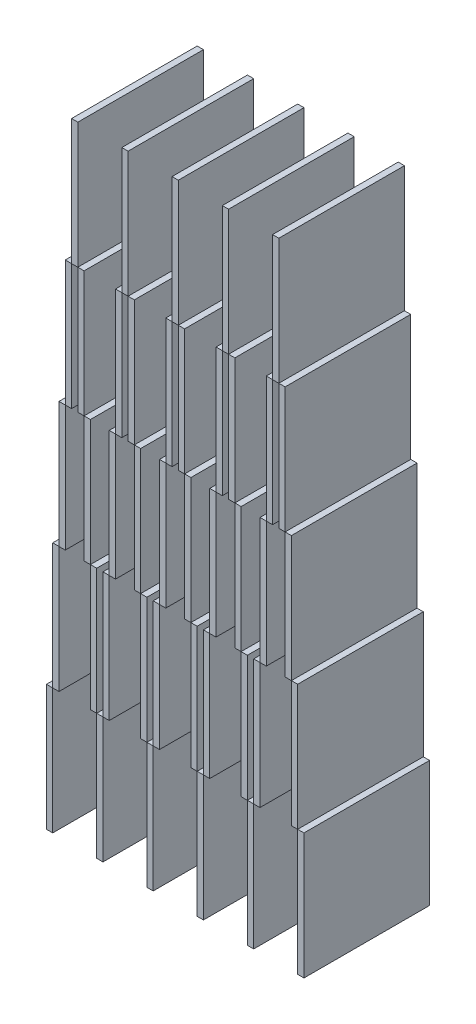
from build123d import *

# Parameters (mm, degrees)
SKETCH1_W              = 1
SKETCH1_H              = 20
BOSS_EXTRUDE1_DEPTH    = 20
BOSS_EXTRUDE1_2_DEPTH  = 20
BOSS_EXTRUDE1_3_DEPTH  = 20
BOSS_EXTRUDE1_4_DEPTH  = 20
BOSS_EXTRUDE1_5_DEPTH  = 20
BOSS_EXTRUDE1_6_DEPTH  = 20
BOSS_EXTRUDE1_7_DEPTH  = 20
BOSS_EXTRUDE1_8_DEPTH  = 20
BOSS_EXTRUDE1_9_DEPTH  = 20
BOSS_EXTRUDE1_10_DEPTH = 20
BOSS_EXTRUDE1_11_DEPTH = 20
BOSS_EXTRUDE1_12_DEPTH = 20
BOSS_EXTRUDE1_13_DEPTH = 20
BOSS_EXTRUDE1_14_DEPTH = 20
BOSS_EXTRUDE1_15_DEPTH = 20
BOSS_EXTRUDE1_16_DEPTH = 20
BOSS_EXTRUDE1_17_DEPTH = 20
BOSS_EXTRUDE1_18_DEPTH = 20
BOSS_EXTRUDE1_19_DEPTH = 20
BOSS_EXTRUDE1_20_DEPTH = 20
BOSS_EXTRUDE1_21_DEPTH = 20
BOSS_EXTRUDE1_22_DEPTH = 20
BOSS_EXTRUDE1_23_DEPTH = 20
BOSS_EXTRUDE1_24_DEPTH = 20
BOSS_EXTRUDE1_25_DEPTH = 20
BOSS_EXTRUDE1_26_DEPTH = 20
BOSS_EXTRUDE1_27_DEPTH = 20
BOSS_EXTRUDE1_28_DEPTH = 20
BOSS_EXTRUDE1_29_DEPTH = 20
BOSS_EXTRUDE1_30_DEPTH = 20
BOSS_EXTRUDE1_31_DEPTH = 20
BOSS_EXTRUDE1_32_DEPTH = 20
BOSS_EXTRUDE1_33_DEPTH = 20
BOSS_EXTRUDE1_34_DEPTH = 20
BOSS_EXTRUDE1_35_DEPTH = 20
BOSS_EXTRUDE1_36_DEPTH = 20
BOSS_EXTRUDE1_37_DEPTH = 20
BOSS_EXTRUDE1_38_DEPTH = 20
BOSS_EXTRUDE1_39_DEPTH = 20
BOSS_EXTRUDE1_40_DEPTH = 20
BOSS_EXTRUDE1_41_DEPTH = 20


with BuildPart() as part:
    # Sketch1 → Boss-Extrude1 (new body)
    with BuildSketch(Plane.XY):
        with Locations((-46.033972916, 14.88459588)):
            Rectangle(SKETCH1_W, SKETCH1_H)
    extrude(amount=BOSS_EXTRUDE1_DEPTH)


with BuildPart() as body_2:
    # Sketch1 → Boss-Extrude1 2 (new body)
    with BuildSketch(Plane.XY):
        with Locations((-45.033972916, 34.88459588)):
            Rectangle(SKETCH1_W, SKETCH1_H)
    extrude(amount=BOSS_EXTRUDE1_2_DEPTH)


with BuildPart() as body_3:
    # Sketch1 → Boss-Extrude1 3 (new body)
    with BuildSketch(Plane.XY):
        with Locations((-39.033972916, 34.88459588)):
            Rectangle(SKETCH1_W, SKETCH1_H)
    extrude(amount=BOSS_EXTRUDE1_3_DEPTH)


with BuildPart() as body_4:
    # Sketch1 → Boss-Extrude1 4 (new body)
    with BuildSketch(Plane.XY):
        with Locations((-37.033972916, 34.88459588)):
            Rectangle(SKETCH1_W, SKETCH1_H)
    extrude(amount=BOSS_EXTRUDE1_4_DEPTH)


with BuildPart() as body_5:
    # Sketch1 → Boss-Extrude1 5 (new body)
    with BuildSketch(Plane.XY):
        with Locations((-38.033972916, 14.88459588)):
            Rectangle(SKETCH1_W, SKETCH1_H)
    extrude(amount=BOSS_EXTRUDE1_5_DEPTH)


with BuildPart() as body_6:
    # Sketch1 → Boss-Extrude1 6 (new body)
    with BuildSketch(Plane.XY):
        with Locations((-31.033972916, 34.88459588)):
            Rectangle(SKETCH1_W, SKETCH1_H)
    extrude(amount=BOSS_EXTRUDE1_6_DEPTH)


with BuildPart() as body_7:
    # Sketch1 → Boss-Extrude1 7 (new body)
    with BuildSketch(Plane.XY):
        with Locations((-29.033972916, 34.88459588)):
            Rectangle(SKETCH1_W, SKETCH1_H)
    extrude(amount=BOSS_EXTRUDE1_7_DEPTH)


with BuildPart() as body_8:
    # Sketch1 → Boss-Extrude1 8 (new body)
    with BuildSketch(Plane.XY):
        with Locations((-30.033972916, 14.88459588)):
            Rectangle(SKETCH1_W, SKETCH1_H)
    extrude(amount=BOSS_EXTRUDE1_8_DEPTH)


with BuildPart() as body_9:
    # Sketch1 → Boss-Extrude1 9 (new body)
    with BuildSketch(Plane.XY):
        with Locations((-23.033972916, 34.88459588)):
            Rectangle(SKETCH1_W, SKETCH1_H)
    extrude(amount=BOSS_EXTRUDE1_9_DEPTH)


with BuildPart() as body_10:
    # Sketch1 → Boss-Extrude1 10 (new body)
    with BuildSketch(Plane.XY):
        with Locations((-21.033972916, 34.88459588)):
            Rectangle(SKETCH1_W, SKETCH1_H)
    extrude(amount=BOSS_EXTRUDE1_10_DEPTH)


with BuildPart() as body_11:
    # Sketch1 → Boss-Extrude1 11 (new body)
    with BuildSketch(Plane.XY):
        with Locations((-22.033972916, 14.88459588)):
            Rectangle(SKETCH1_W, SKETCH1_H)
    extrude(amount=BOSS_EXTRUDE1_11_DEPTH)


with BuildPart() as body_12:
    # Sketch1 → Boss-Extrude1 12 (new body)
    with BuildSketch(Plane.XY):
        with Locations((-6.033972916, 14.88459588)):
            Rectangle(SKETCH1_W, SKETCH1_H)
    extrude(amount=BOSS_EXTRUDE1_12_DEPTH)


with BuildPart() as body_13:
    # Sketch1 → Boss-Extrude1 13 (new body)
    with BuildSketch(Plane.XY):
        with Locations((-14.033972916, 14.88459588)):
            Rectangle(SKETCH1_W, SKETCH1_H)
    extrude(amount=BOSS_EXTRUDE1_13_DEPTH)


with BuildPart() as body_14:
    # Sketch1 → Boss-Extrude1 14 (new body)
    with BuildSketch(Plane.XY):
        with Locations((-15.033972916, 34.88459588)):
            Rectangle(SKETCH1_W, SKETCH1_H)
    extrude(amount=BOSS_EXTRUDE1_14_DEPTH)


with BuildPart() as body_15:
    # Sketch1 → Boss-Extrude1 15 (new body)
    with BuildSketch(Plane.XY):
        with Locations((-13.033972916, 34.88459588)):
            Rectangle(SKETCH1_W, SKETCH1_H)
    extrude(amount=BOSS_EXTRUDE1_15_DEPTH)


with BuildPart() as body_16:
    # Sketch1 → Boss-Extrude1 16 (new body)
    with BuildSketch(Plane.XY):
        with Locations((-7.033972916, 34.88459588)):
            Rectangle(SKETCH1_W, SKETCH1_H)
    extrude(amount=BOSS_EXTRUDE1_16_DEPTH)


with BuildPart() as body_17:
    # Sketch1 → Boss-Extrude1 17 (new body)
    with BuildSketch(Plane.XY):
        with Locations((-44.033972916, 54.88459588)):
            Rectangle(SKETCH1_W, SKETCH1_H)
    extrude(amount=BOSS_EXTRUDE1_17_DEPTH)


with BuildPart() as body_18:
    # Sketch1 → Boss-Extrude1 18 (new body)
    with BuildSketch(Plane.XY):
        with Locations((-36.033972916, 54.88459588)):
            Rectangle(SKETCH1_W, SKETCH1_H)
    extrude(amount=BOSS_EXTRUDE1_18_DEPTH)


with BuildPart() as body_19:
    # Sketch1 → Boss-Extrude1 19 (new body)
    with BuildSketch(Plane.XY):
        with Locations((-32.033972916, 54.88459588)):
            Rectangle(SKETCH1_W, SKETCH1_H)
    extrude(amount=BOSS_EXTRUDE1_19_DEPTH)


with BuildPart() as body_20:
    # Sketch1 → Boss-Extrude1 20 (new body)
    with BuildSketch(Plane.XY):
        with Locations((-43.033972916, 74.88459588)):
            Rectangle(SKETCH1_W, SKETCH1_H)
    extrude(amount=BOSS_EXTRUDE1_20_DEPTH)


with BuildPart() as body_21:
    # Sketch1 → Boss-Extrude1 21 (new body)
    with BuildSketch(Plane.XY):
        with Locations((-41.033972916, 74.88459588)):
            Rectangle(SKETCH1_W, SKETCH1_H)
    extrude(amount=BOSS_EXTRUDE1_21_DEPTH)


with BuildPart() as body_22:
    # Sketch1 → Boss-Extrude1 22 (new body)
    with BuildSketch(Plane.XY):
        with Locations((-35.033972916, 74.88459588)):
            Rectangle(SKETCH1_W, SKETCH1_H)
    extrude(amount=BOSS_EXTRUDE1_22_DEPTH)


with BuildPart() as body_23:
    # Sketch1 → Boss-Extrude1 23 (new body)
    with BuildSketch(Plane.XY):
        with Locations((-33.033972916, 74.88459588)):
            Rectangle(SKETCH1_W, SKETCH1_H)
    extrude(amount=BOSS_EXTRUDE1_23_DEPTH)


with BuildPart() as body_24:
    # Sketch1 → Boss-Extrude1 24 (new body)
    with BuildSketch(Plane.XY):
        with Locations((-28.033972916, 54.88459588)):
            Rectangle(SKETCH1_W, SKETCH1_H)
    extrude(amount=BOSS_EXTRUDE1_24_DEPTH)


with BuildPart() as body_25:
    # Sketch1 → Boss-Extrude1 25 (new body)
    with BuildSketch(Plane.XY):
        with Locations((-27.033972916, 74.88459588)):
            Rectangle(SKETCH1_W, SKETCH1_H)
    extrude(amount=BOSS_EXTRUDE1_25_DEPTH)


with BuildPart() as body_26:
    # Sketch1 → Boss-Extrude1 26 (new body)
    with BuildSketch(Plane.XY):
        with Locations((-25.033972916, 74.88459588)):
            Rectangle(SKETCH1_W, SKETCH1_H)
    extrude(amount=BOSS_EXTRUDE1_26_DEPTH)


with BuildPart() as body_27:
    # Sketch1 → Boss-Extrude1 27 (new body)
    with BuildSketch(Plane.XY):
        with Locations((-24.033972916, 54.88459588)):
            Rectangle(SKETCH1_W, SKETCH1_H)
    extrude(amount=BOSS_EXTRUDE1_27_DEPTH)


with BuildPart() as body_28:
    # Sketch1 → Boss-Extrude1 28 (new body)
    with BuildSketch(Plane.XY):
        with Locations((-20.033972916, 54.88459588)):
            Rectangle(SKETCH1_W, SKETCH1_H)
    extrude(amount=BOSS_EXTRUDE1_28_DEPTH)


with BuildPart() as body_29:
    # Sketch1 → Boss-Extrude1 29 (new body)
    with BuildSketch(Plane.XY):
        with Locations((-19.033972916, 74.88459588)):
            Rectangle(SKETCH1_W, SKETCH1_H)
    extrude(amount=BOSS_EXTRUDE1_29_DEPTH)


with BuildPart() as body_30:
    # Sketch1 → Boss-Extrude1 30 (new body)
    with BuildSketch(Plane.XY):
        with Locations((-17.033972916, 74.88459588)):
            Rectangle(SKETCH1_W, SKETCH1_H)
    extrude(amount=BOSS_EXTRUDE1_30_DEPTH)


with BuildPart() as body_31:
    # Sketch1 → Boss-Extrude1 31 (new body)
    with BuildSketch(Plane.XY):
        with Locations((-16.033972916, 54.88459588)):
            Rectangle(SKETCH1_W, SKETCH1_H)
    extrude(amount=BOSS_EXTRUDE1_31_DEPTH)


with BuildPart() as body_32:
    # Sketch1 → Boss-Extrude1 32 (new body)
    with BuildSketch(Plane.XY):
        with Locations((-12.033972916, 54.88459588)):
            Rectangle(SKETCH1_W, SKETCH1_H)
    extrude(amount=BOSS_EXTRUDE1_32_DEPTH)


with BuildPart() as body_33:
    # Sketch1 → Boss-Extrude1 33 (new body)
    with BuildSketch(Plane.XY):
        with Locations((-11.033972916, 74.88459588)):
            Rectangle(SKETCH1_W, SKETCH1_H)
    extrude(amount=BOSS_EXTRUDE1_33_DEPTH)


with BuildPart() as body_34:
    # Sketch1 → Boss-Extrude1 34 (new body)
    with BuildSketch(Plane.XY):
        with Locations((-9.033972916, 74.88459588)):
            Rectangle(SKETCH1_W, SKETCH1_H)
    extrude(amount=BOSS_EXTRUDE1_34_DEPTH)


with BuildPart() as body_35:
    # Sketch1 → Boss-Extrude1 35 (new body)
    with BuildSketch(Plane.XY):
        with Locations((-8.033972916, 54.88459588)):
            Rectangle(SKETCH1_W, SKETCH1_H)
    extrude(amount=BOSS_EXTRUDE1_35_DEPTH)


with BuildPart() as body_36:
    # Sketch1 → Boss-Extrude1 36 (new body)
    with BuildSketch(Plane.XY):
        with Locations((-42.033972916, 94.88459588)):
            Rectangle(SKETCH1_W, SKETCH1_H)
    extrude(amount=BOSS_EXTRUDE1_36_DEPTH)


with BuildPart() as body_37:
    # Sketch1 → Boss-Extrude1 37 (new body)
    with BuildSketch(Plane.XY):
        with Locations((-34.033972916, 94.88459588)):
            Rectangle(SKETCH1_W, SKETCH1_H)
    extrude(amount=BOSS_EXTRUDE1_37_DEPTH)


with BuildPart() as body_38:
    # Sketch1 → Boss-Extrude1 38 (new body)
    with BuildSketch(Plane.XY):
        with Locations((-26.033972916, 94.88459588)):
            Rectangle(SKETCH1_W, SKETCH1_H)
    extrude(amount=BOSS_EXTRUDE1_38_DEPTH)


with BuildPart() as body_39:
    # Sketch1 → Boss-Extrude1 39 (new body)
    with BuildSketch(Plane.XY):
        with Locations((-18.033972916, 94.88459588)):
            Rectangle(SKETCH1_W, SKETCH1_H)
    extrude(amount=BOSS_EXTRUDE1_39_DEPTH)


with BuildPart() as body_40:
    # Sketch1 → Boss-Extrude1 40 (new body)
    with BuildSketch(Plane.XY):
        with Locations((-10.033972916, 94.88459588)):
            Rectangle(SKETCH1_W, SKETCH1_H)
    extrude(amount=BOSS_EXTRUDE1_40_DEPTH)


with BuildPart() as body_41:
    # Sketch1 → Boss-Extrude1 41 (new body)
    with BuildSketch(Plane.XY):
        with Locations((-40.033972916, 54.88459588)):
            Rectangle(SKETCH1_W, SKETCH1_H)
    extrude(amount=BOSS_EXTRUDE1_41_DEPTH)


solid = Compound([part.part, body_2.part, body_3.part, body_4.part, body_5.part, body_6.part, body_7.part, body_8.part, body_9.part, body_10.part, body_11.part, body_12.part, body_13.part, body_14.part, body_15.part, body_16.part, body_17.part, body_18.part, body_19.part, body_20.part, body_21.part, body_22.part, body_23.part, body_24.part, body_25.part, body_26.part, body_27.part, body_28.part, body_29.part, body_30.part, body_31.part, body_32.part, body_33.part, body_34.part, body_35.part, body_36.part, body_37.part, body_38.part, body_39.part, body_40.part, body_41.part])
